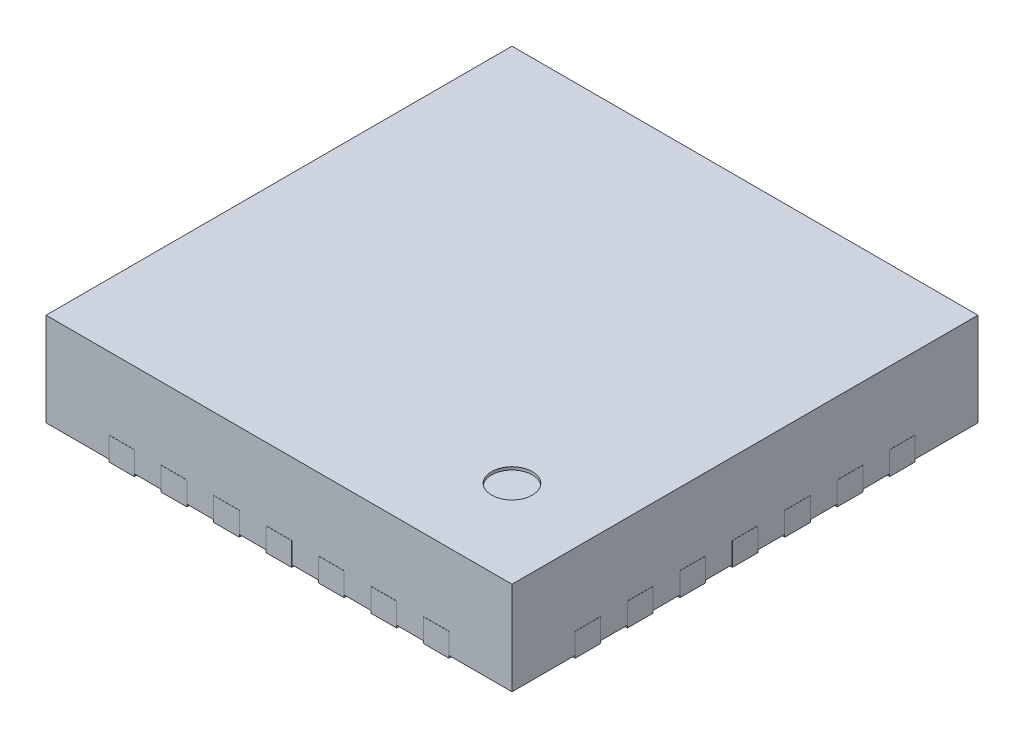
from build123d import *

# Parameters (mm, degrees)
SKETCH1_W                = 4
SKETCH1_H                = 4
BOSS_EXTRUDE1_DEPTH      = 0.8
SKETCH2_R                = 0.175
CUT_EXTRUDE1_DEPTH       = 0.025
BOSS_EXTRUDE2_DEPTH      = 0.01
BOSS_EXTRUDE3_DEPTH      = 0.02
BOSS_EXTRUDE3_DEPTH_BACK = 0.18


with BuildPart() as part:
    # Sketch1 → Boss-Extrude1 (new body)
    with BuildSketch(Plane(origin=(0, 0, 0), x_dir=(1, 0, 0), z_dir=(0, 1, 0))):
        Rectangle(SKETCH1_W, SKETCH1_H)
    extrude(amount=BOSS_EXTRUDE1_DEPTH)

    # Sketch2 → Cut-Extrude1 (cut)
    with BuildSketch(Plane(origin=(0, 0.8, 0), x_dir=(-1, 0, 0), z_dir=(0, 1, 0))):
        with Locations((-1.25, 1.25)):
            Circle(SKETCH2_R)
    extrude(amount=-CUT_EXTRUDE1_DEPTH, mode=Mode.SUBTRACT)

    # Sketch3 → Boss-Extrude2 (add)
    with BuildSketch(Plane.XZ):
        with BuildLine():
            Line((1.2, 0.95), (1.2, 1))
            ThreePointArc((1.2, 1), (1.141421356, 1.141421356), (1, 1.2))
            Line((1, 1.2), (-1, 1.2))
            ThreePointArc((-1, 1.2), (-1.141421356, 1.141421356), (-1.2, 1))
            Line((-1.2, 1), (-1.2, -1))
            ThreePointArc((-1.2, -1), (-1.141421356, -1.141421356), (-1, -1.2))
            Line((-1, -1.2), (1, -1.2))
            ThreePointArc((1, -1.2), (1.141421356, -1.141421356), (1.2, -1))
            Line((1.2, -1), (1.2, 0.55))
            ThreePointArc((1.2, 0.55), (1, 0.75), (1.2, 0.95))
        make_face()
    extrude(amount=BOSS_EXTRUDE2_DEPTH)

    # Sketch4 → Boss-Extrude3 (add, two sides)
    with BuildSketch(Plane.XZ) as boss_extrude3_sk:
        with BuildLine():
            Line((1.46, 1.598964458), (1.261035542, 1.4))
            ThreePointArc((1.261035542, 1.4), (1.245390989, 1.430680051), (1.24, 1.46469409))
            Line((1.24, 1.46469409), (1.24, 2.001))
            Line((1.24, 2.001), (1.46, 2.001))
            Line((1.46, 2.001), (1.46, 1.598964458))
        make_face()
        with BuildLine():
            Line((-1.46, 2.001), (-1.24, 2.001))
            Line((-1.24, 2.001), (-1.24, 1.46469409))
            ThreePointArc((-1.24, 1.46469409), (-1.245390989, 1.430680051), (-1.261035542, 1.4))
            Line((-1.261035542, 1.4), (-1.46, 1.598964458))
            Line((-1.46, 1.598964458), (-1.46, 2.001))
        make_face()
        with BuildLine():
            Line((-1.01, 2.001), (-0.79, 2.001))
            Line((-0.79, 2.001), (-0.79, 1.46469409))
            ThreePointArc((-0.79, 1.46469409), (-0.9, 1.35469409), (-1.01, 1.46469409))
            Line((-1.01, 1.46469409), (-1.01, 2.001))
        make_face()
        with BuildLine():
            Line((-0.56, 2.001), (-0.34, 2.001))
            Line((-0.34, 2.001), (-0.34, 1.46469409))
            ThreePointArc((-0.34, 1.46469409), (-0.45, 1.35469409), (-0.56, 1.46469409))
            Line((-0.56, 1.46469409), (-0.56, 2.001))
        make_face()
        with BuildLine():
            Line((-0.11, 2.001), (0.11, 2.001))
            Line((0.11, 2.001), (0.11, 1.46469409))
            ThreePointArc((0.11, 1.46469409), (0, 1.35469409), (-0.11, 1.46469409))
            Line((-0.11, 1.46469409), (-0.11, 2.001))
        make_face()
        with BuildLine():
            Line((0.34, 2.001), (0.56, 2.001))
            Line((0.56, 2.001), (0.56, 1.46469409))
            ThreePointArc((0.56, 1.46469409), (0.45, 1.35469409), (0.34, 1.46469409))
            Line((0.34, 1.46469409), (0.34, 2.001))
        make_face()
        with BuildLine():
            Line((0.79, 2.001), (1.01, 2.001))
            Line((1.01, 2.001), (1.01, 1.46469409))
            ThreePointArc((1.01, 1.46469409), (0.9, 1.35469409), (0.79, 1.46469409))
            Line((0.79, 1.46469409), (0.79, 2.001))
        make_face()
        with BuildLine():
            Line((1.598964458, -1.46), (1.4, -1.261035542))
            ThreePointArc((1.4, -1.261035542), (1.430680051, -1.245390989), (1.46469409, -1.24))
            Line((1.46469409, -1.24), (2.001, -1.24))
            Line((2.001, -1.24), (2.001, -1.46))
            Line((2.001, -1.46), (1.598964458, -1.46))
        make_face()
        with BuildLine():
            Line((2.001, 1.46), (2.001, 1.24))
            Line((2.001, 1.24), (1.46469409, 1.24))
            ThreePointArc((1.46469409, 1.24), (1.430680051, 1.245390989), (1.4, 1.261035542))
            Line((1.4, 1.261035542), (1.598964458, 1.46))
            Line((1.598964458, 1.46), (2.001, 1.46))
        make_face()
        with BuildLine():
            Line((2.001, 1.01), (2.001, 0.79))
            Line((2.001, 0.79), (1.46469409, 0.79))
            ThreePointArc((1.46469409, 0.79), (1.35469409, 0.9), (1.46469409, 1.01))
            Line((1.46469409, 1.01), (2.001, 1.01))
        make_face()
        with BuildLine():
            Line((2.001, 0.56), (2.001, 0.34))
            Line((2.001, 0.34), (1.46469409, 0.34))
            ThreePointArc((1.46469409, 0.34), (1.35469409, 0.45), (1.46469409, 0.56))
            Line((1.46469409, 0.56), (2.001, 0.56))
        make_face()
        with BuildLine():
            Line((2.001, 0.11), (2.001, -0.11))
            Line((2.001, -0.11), (1.46469409, -0.11))
            ThreePointArc((1.46469409, -0.11), (1.35469409, 0), (1.46469409, 0.11))
            Line((1.46469409, 0.11), (2.001, 0.11))
        make_face()
        with BuildLine():
            Line((2.001, -0.34), (2.001, -0.56))
            Line((2.001, -0.56), (1.46469409, -0.56))
            ThreePointArc((1.46469409, -0.56), (1.35469409, -0.45), (1.46469409, -0.34))
            Line((1.46469409, -0.34), (2.001, -0.34))
        make_face()
        with BuildLine():
            Line((2.001, -0.79), (2.001, -1.01))
            Line((2.001, -1.01), (1.46469409, -1.01))
            ThreePointArc((1.46469409, -1.01), (1.35469409, -0.9), (1.46469409, -0.79))
            Line((1.46469409, -0.79), (2.001, -0.79))
        make_face()
        with BuildLine():
            Line((-1.46, -1.598964458), (-1.261035542, -1.4))
            ThreePointArc((-1.261035542, -1.4), (-1.245390989, -1.430680051), (-1.24, -1.46469409))
            Line((-1.24, -1.46469409), (-1.24, -2.001))
            Line((-1.24, -2.001), (-1.46, -2.001))
            Line((-1.46, -2.001), (-1.46, -1.598964458))
        make_face()
        with BuildLine():
            Line((1.46, -2.001), (1.24, -2.001))
            Line((1.24, -2.001), (1.24, -1.46469409))
            ThreePointArc((1.24, -1.46469409), (1.245390989, -1.430680051), (1.261035542, -1.4))
            Line((1.261035542, -1.4), (1.46, -1.598964458))
            Line((1.46, -1.598964458), (1.46, -2.001))
        make_face()
        with BuildLine():
            Line((1.01, -2.001), (0.79, -2.001))
            Line((0.79, -2.001), (0.79, -1.46469409))
            ThreePointArc((0.79, -1.46469409), (0.9, -1.35469409), (1.01, -1.46469409))
            Line((1.01, -1.46469409), (1.01, -2.001))
        make_face()
        with BuildLine():
            Line((0.56, -2.001), (0.34, -2.001))
            Line((0.34, -2.001), (0.34, -1.46469409))
            ThreePointArc((0.34, -1.46469409), (0.45, -1.35469409), (0.56, -1.46469409))
            Line((0.56, -1.46469409), (0.56, -2.001))
        make_face()
        with BuildLine():
            Line((0.11, -2.001), (-0.11, -2.001))
            Line((-0.11, -2.001), (-0.11, -1.46469409))
            ThreePointArc((-0.11, -1.46469409), (0, -1.35469409), (0.11, -1.46469409))
            Line((0.11, -1.46469409), (0.11, -2.001))
        make_face()
        with BuildLine():
            Line((-0.34, -2.001), (-0.56, -2.001))
            Line((-0.56, -2.001), (-0.56, -1.46469409))
            ThreePointArc((-0.56, -1.46469409), (-0.45, -1.35469409), (-0.34, -1.46469409))
            Line((-0.34, -1.46469409), (-0.34, -2.001))
        make_face()
        with BuildLine():
            Line((-0.79, -2.001), (-1.01, -2.001))
            Line((-1.01, -2.001), (-1.01, -1.46469409))
            ThreePointArc((-1.01, -1.46469409), (-0.9, -1.35469409), (-0.79, -1.46469409))
            Line((-0.79, -1.46469409), (-0.79, -2.001))
        make_face()
        with BuildLine():
            Line((-1.598964458, 1.46), (-1.4, 1.261035542))
            ThreePointArc((-1.4, 1.261035542), (-1.430680051, 1.245390989), (-1.46469409, 1.24))
            Line((-1.46469409, 1.24), (-2.001, 1.24))
            Line((-2.001, 1.24), (-2.001, 1.46))
            Line((-2.001, 1.46), (-1.598964458, 1.46))
        make_face()
        with BuildLine():
            Line((-2.001, -1.46), (-2.001, -1.24))
            Line((-2.001, -1.24), (-1.46469409, -1.24))
            ThreePointArc((-1.46469409, -1.24), (-1.430680051, -1.245390989), (-1.4, -1.261035542))
            Line((-1.4, -1.261035542), (-1.598964458, -1.46))
            Line((-1.598964458, -1.46), (-2.001, -1.46))
        make_face()
        with BuildLine():
            Line((-2.001, -1.01), (-2.001, -0.79))
            Line((-2.001, -0.79), (-1.46469409, -0.79))
            ThreePointArc((-1.46469409, -0.79), (-1.35469409, -0.9), (-1.46469409, -1.01))
            Line((-1.46469409, -1.01), (-2.001, -1.01))
        make_face()
        with BuildLine():
            Line((-2.001, -0.56), (-2.001, -0.34))
            Line((-2.001, -0.34), (-1.46469409, -0.34))
            ThreePointArc((-1.46469409, -0.34), (-1.35469409, -0.45), (-1.46469409, -0.56))
            Line((-1.46469409, -0.56), (-2.001, -0.56))
        make_face()
        with BuildLine():
            Line((-2.001, -0.11), (-2.001, 0.11))
            Line((-2.001, 0.11), (-1.46469409, 0.11))
            ThreePointArc((-1.46469409, 0.11), (-1.35469409, 0), (-1.46469409, -0.11))
            Line((-1.46469409, -0.11), (-2.001, -0.11))
        make_face()
        with BuildLine():
            Line((-2.001, 0.34), (-2.001, 0.56))
            Line((-2.001, 0.56), (-1.46469409, 0.56))
            ThreePointArc((-1.46469409, 0.56), (-1.35469409, 0.45), (-1.46469409, 0.34))
            Line((-1.46469409, 0.34), (-2.001, 0.34))
        make_face()
        with BuildLine():
            Line((-2.001, 0.79), (-2.001, 1.01))
            Line((-2.001, 1.01), (-1.46469409, 1.01))
            ThreePointArc((-1.46469409, 1.01), (-1.35469409, 0.9), (-1.46469409, 0.79))
            Line((-1.46469409, 0.79), (-2.001, 0.79))
        make_face()
    extrude(amount=BOSS_EXTRUDE3_DEPTH)
    extrude(boss_extrude3_sk.sketch, amount=-BOSS_EXTRUDE3_DEPTH_BACK)


solid = part.part
